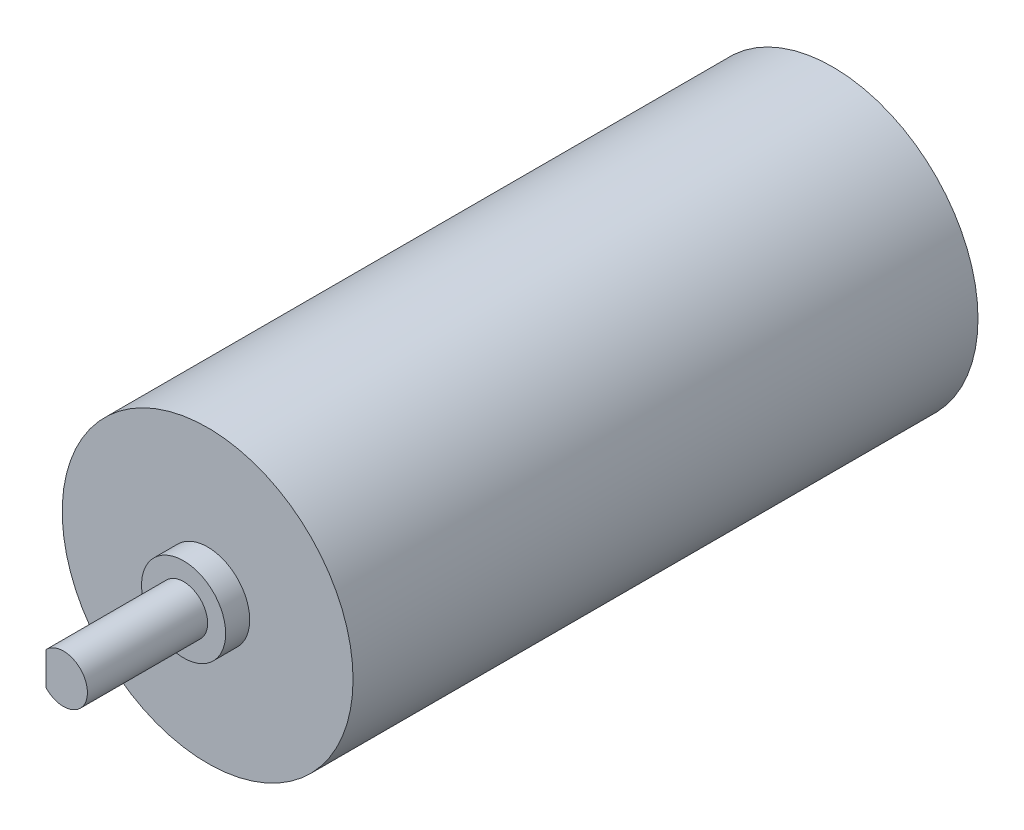
from build123d import *

# Parameters (mm, degrees)
SKETCH1_R           = 12.1
BOSS_EXTRUDE1_DEPTH = 52
SKETCH2_R           = 3.5
BOSS_EXTRUDE2_DEPTH = 2
BOSS_EXTRUDE3_DEPTH = 10


with BuildPart() as part:
    # Sketch1 → Boss-Extrude1 (new body)
    with BuildSketch(Plane.XY):
        Circle(SKETCH1_R)
    extrude(amount=BOSS_EXTRUDE1_DEPTH)

    # Sketch2 → Boss-Extrude2 (add)
    with BuildSketch(Plane.XY.offset(52)):
        Circle(SKETCH2_R)
    extrude(amount=BOSS_EXTRUDE2_DEPTH)

    # Sketch4 → Boss-Extrude3 (add)
    with BuildSketch(Plane.XY.offset(54)):
        with BuildLine():
            Line((-1.449347592, 1.378184152), (-1.449347592, -1.378184152))
            ThreePointArc((-1.449347592, -1.378184152), (2, 0), (-1.449347592, 1.378184152))
        make_face()
    extrude(amount=BOSS_EXTRUDE3_DEPTH)


solid = part.part
